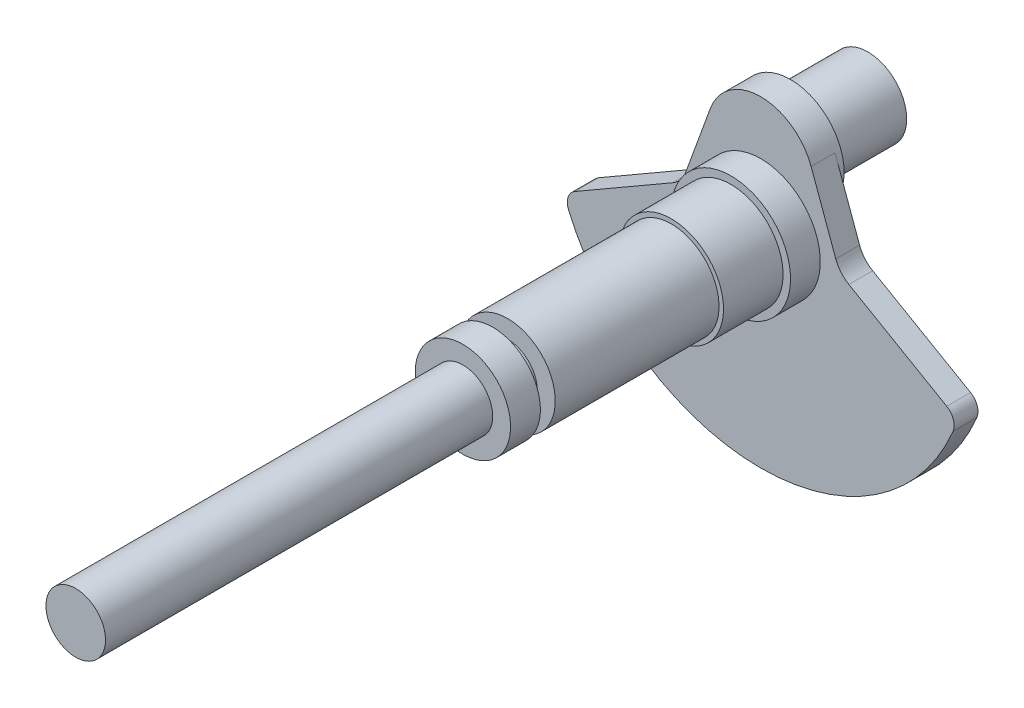
from build123d import *

# Parameters (mm, degrees)
SKETCH1_R            = 10
BOSS_EXTRUDE1_DEPTH  = 130
SKETCH2_R            = 16
BOSS_EXTRUDE2_DEPTH  = 10
SKETCH3_R            = 10
BOSS_EXTRUDE4_DEPTH  = 5
SKETCH6_R            = 16
BOSS_EXTRUDE5_DEPTH  = 55
SKETCH7_R            = 17.5
BOSS_EXTRUDE6_DEPTH  = 20
SKETCH8_R            = 20
BOSS_EXTRUDE7_DEPTH  = 10
SKETCH9_R            = 18
BOSS_EXTRUDE8_DEPTH  = 10
SKETCH10_R           = 13
BOSS_EXTRUDE9_DEPTH  = 26
BOSS_EXTRUDE10_DEPTH = 8


with BuildPart() as part:
    # Sketch1 → Boss-Extrude1 (new body)
    with BuildSketch(Plane.XY):
        Circle(SKETCH1_R)
    extrude(amount=-BOSS_EXTRUDE1_DEPTH)

    # Sketch2 → Boss-Extrude2 (add)
    with BuildSketch(Plane(origin=(0, 0, -130), x_dir=(-1, 0, 0), z_dir=(0, 0, -1))):
        Circle(SKETCH2_R)
    extrude(amount=BOSS_EXTRUDE2_DEPTH)

    # Sketch3 → Boss-Extrude4 (add)
    with BuildSketch(Plane(origin=(0, 0, -140), x_dir=(-1, 0, 0), z_dir=(0, 0, -1))):
        Circle(SKETCH3_R)
    extrude(amount=BOSS_EXTRUDE4_DEPTH)

    # Sketch6 → Boss-Extrude5 (add)
    with BuildSketch(Plane(origin=(0, 0, -145), x_dir=(-1, 0, 0), z_dir=(0, 0, -1))):
        Circle(SKETCH6_R)
    extrude(amount=BOSS_EXTRUDE5_DEPTH)

    # Sketch7 → Boss-Extrude6 (add)
    with BuildSketch(Plane(origin=(0, 0, -200), x_dir=(-1, 0, 0), z_dir=(0, 0, -1))):
        Circle(SKETCH7_R)
    extrude(amount=BOSS_EXTRUDE6_DEPTH)

    # Sketch8 → Boss-Extrude7 (add)
    with BuildSketch(Plane(origin=(0, 0, -220), x_dir=(-1, 0, 0), z_dir=(0, 0, -1))):
        Circle(SKETCH8_R)
    extrude(amount=BOSS_EXTRUDE7_DEPTH)

    # Sketch9 → Boss-Extrude8 (add)
    with BuildSketch(Plane(origin=(0, 0, -230), x_dir=(-1, 0, 0), z_dir=(0, 0, -1))):
        with Locations((0, 20)):
            Circle(SKETCH9_R)
    extrude(amount=BOSS_EXTRUDE8_DEPTH)

    # Sketch10 → Boss-Extrude9 (add)
    with BuildSketch(Plane(origin=(0, 0, -240), x_dir=(-1, 0, 0), z_dir=(0, 0, -1))):
        with Locations((0, 20)):
            Circle(SKETCH10_R)
    extrude(amount=BOSS_EXTRUDE9_DEPTH)

    # Sketch11 → Boss-Extrude10 (add)
    with BuildSketch(Plane.XY.offset(-230)):
        with BuildLine():
            Line((-16.914467174, 26.15636258), (-25.189753073, 3.420201433))
            ThreePointArc((-25.189753073, 3.420201433), (-26.92623485, 0.41252677), (-29.586679281, -1.819851171))
            Line((-29.586679281, -1.819851171), (-62.4486633, -20.792726491))
            ThreePointArc((-62.4486633, -20.792726491), (-64.686631077, -23.525461465), (-64.560098939, -27.055380703))
            ThreePointArc((-64.560098939, -27.055380703), (0, -70), (64.560098939, -27.055380703))
            ThreePointArc((64.560098939, -27.055380703), (64.686631077, -23.525461465), (62.4486633, -20.792726491))
            Line((62.4486633, -20.792726491), (29.586679281, -1.819851171))
            ThreePointArc((29.586679281, -1.819851171), (26.92623485, 0.41252677), (25.189753073, 3.420201433))
            Line((25.189753073, 3.420201433), (16.914467174, 26.15636258))
            ThreePointArc((16.914467174, 26.15636258), (0, 2), (-16.914467174, 26.15636258))
        make_face()
    extrude(amount=-BOSS_EXTRUDE10_DEPTH)


solid = part.part
